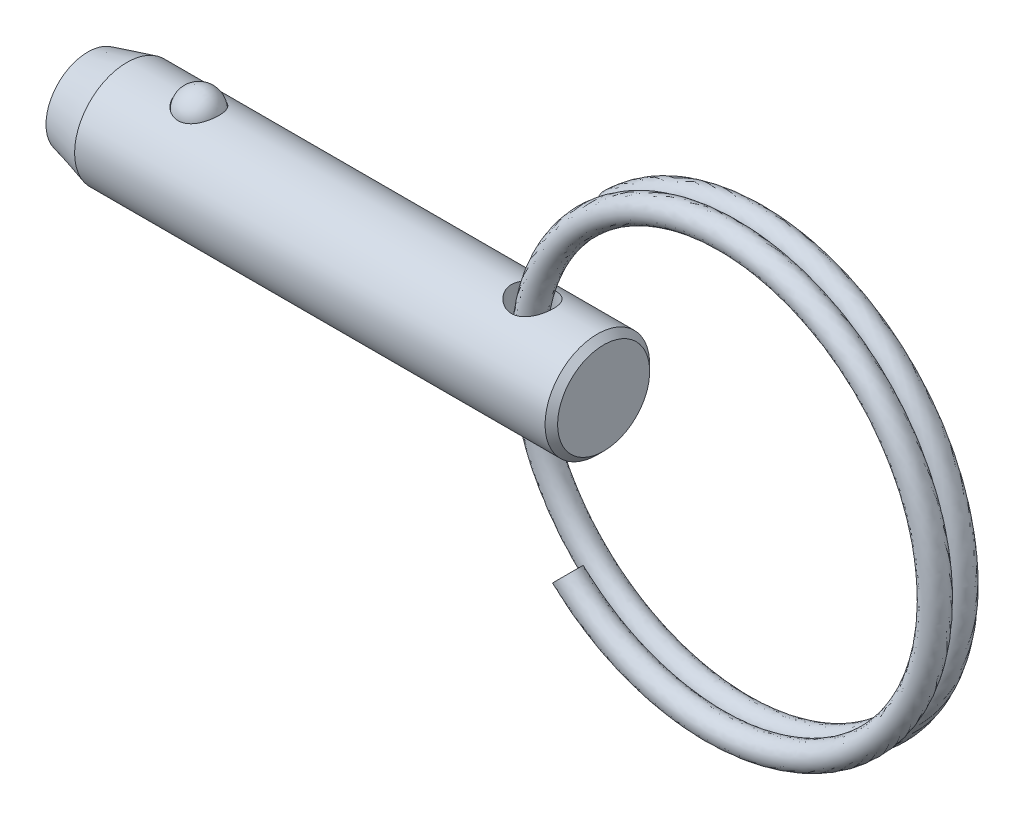
from build123d import *

# Parameters (mm, degrees)
SKETCH4_W          = 1.27
SKETCH4_H          = 6.35
SWEEP1_PITCH       = 1.5494
SWEEP1_HEIGHT      = 1.355725
SWEEP1_RADIUS      = 13.462
SKETCH6_R          = 0.762
SWEEP2_PITCH       = 1.5494
SWEEP2_HEIGHT      = 1.355725
SWEEP2_RADIUS      = 13.462
SWEEP2_START_ANGLE = -180
SKETCH6_2_R        = 0.762


with BuildPart() as part:
    # Sketch1 → Revolve1 (revolve)
    with BuildSketch(Plane.XY):
        Polygon((15.6464, 2.794), (15.2654, 3.175), (-13.276547737, 3.175), (-15.6464, 2.54), (-15.6464, 0), (15.6464, 0), align=None)
    revolve(axis=Axis((15.6464, 0, 0), (1, 0, 0)))

    # Sketch2 → Cut-Revolve1 (revolve, cut)
    with BuildSketch(Plane.XY):
        with BuildLine():
            Line((-7.654582051, 2.8575), (-10.169182051, 2.8575))
            ThreePointArc((-10.169182051, 2.8575), (-8.911882051, 4.1148), (-7.654582051, 2.8575))
        make_face()
    revolve(axis=Axis((-7.654582051, 2.8575, 0), (1, 0, 0)), mode=Mode.SUBTRACT)

    # Sketch4 → Cut-Revolve2 (revolve, cut)
    with BuildSketch(Plane.XY):
        with Locations((11.9634, 0)):
            Rectangle(SKETCH4_W, SKETCH4_H)
    revolve(axis=Axis((11.3284, -3.175, 0), (0, 1, 0)), mode=Mode.SUBTRACT)


with BuildPart() as body_2:
    # Sketch3 → Revolve2 (revolve)
    with BuildSketch(Plane.XY):
        with BuildLine():
            Line((-7.679982051, 2.8575), (-10.143782051, 2.8575))
            ThreePointArc((-10.143782051, 2.8575), (-8.911882051, 4.0894), (-7.679982051, 2.8575))
        make_face()
    revolve(axis=Axis((-7.679982051, 2.8575, 0), (1, 0, 0)))


with BuildPart() as body_3:
    # Sweep1: sweep along a helix
    with BuildLine() as sweep1_path:
        Helix(SWEEP1_PITCH, SWEEP1_HEIGHT, SWEEP1_RADIUS, center=(23.813425091, 0, 0), direction=(0, 0, -1), lefthand=True)
    # Sketch6 → Sweep1 (sweep)
    with BuildSketch(Plane(origin=(114.003847968, 0, 0), x_dir=(0, 0, -1), z_dir=(0, 1, 0))):
        with Locations((0, 102.890422877)):
            Circle(SKETCH6_R)
    sweep(path=sweep1_path.line, is_frenet=True)

    # Sweep2: sweep along a helix
    with BuildLine() as sweep2_path:
        add(Helix(SWEEP2_PITCH, SWEEP2_HEIGHT, SWEEP2_RADIUS, center=(23.813425091, 0, 0), direction=(0, 0, 1), lefthand=True, mode=Mode.PRIVATE).rotate(Axis((23.813425091, 0, 0), (0, 0, 1)), SWEEP2_START_ANGLE))
    # Sketch6_2 → Sweep2 (sweep)
    with BuildSketch(Plane(origin=(114.003847968, 0, 0), x_dir=(0, 0, -1), z_dir=(0, 1, 0))):
        with Locations((0, 102.890422877)):
            Circle(SKETCH6_2_R)
    sweep(path=sweep2_path.line, is_frenet=True)


solid = Compound([part.part, body_2.part, body_3.part])
